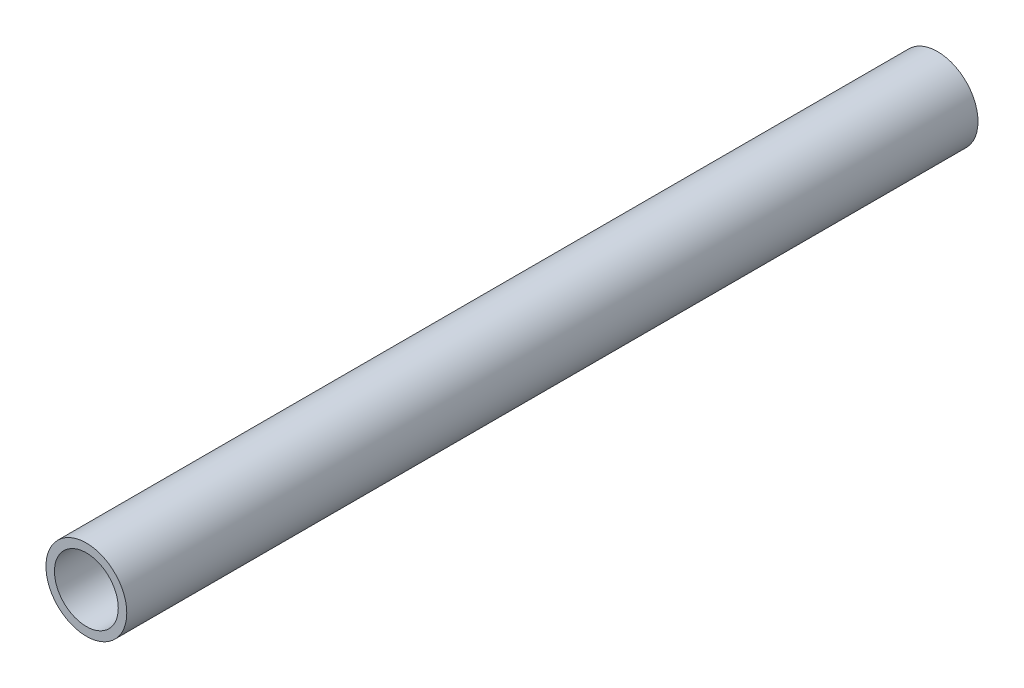
from build123d import *

# Parameters (mm, degrees)
SKETCH_1_R      = 9.5
SKETCH_1_R_2    = 7.5
EXTRUDE_1_DEPTH = 200


with BuildPart() as part:
    # 草圖1 → 填料-伸長1 (new body)
    with BuildSketch(Plane.XY):
        Circle(SKETCH_1_R)
        Circle(SKETCH_1_R_2, mode=Mode.SUBTRACT)
    extrude(amount=EXTRUDE_1_DEPTH)


solid = part.part
